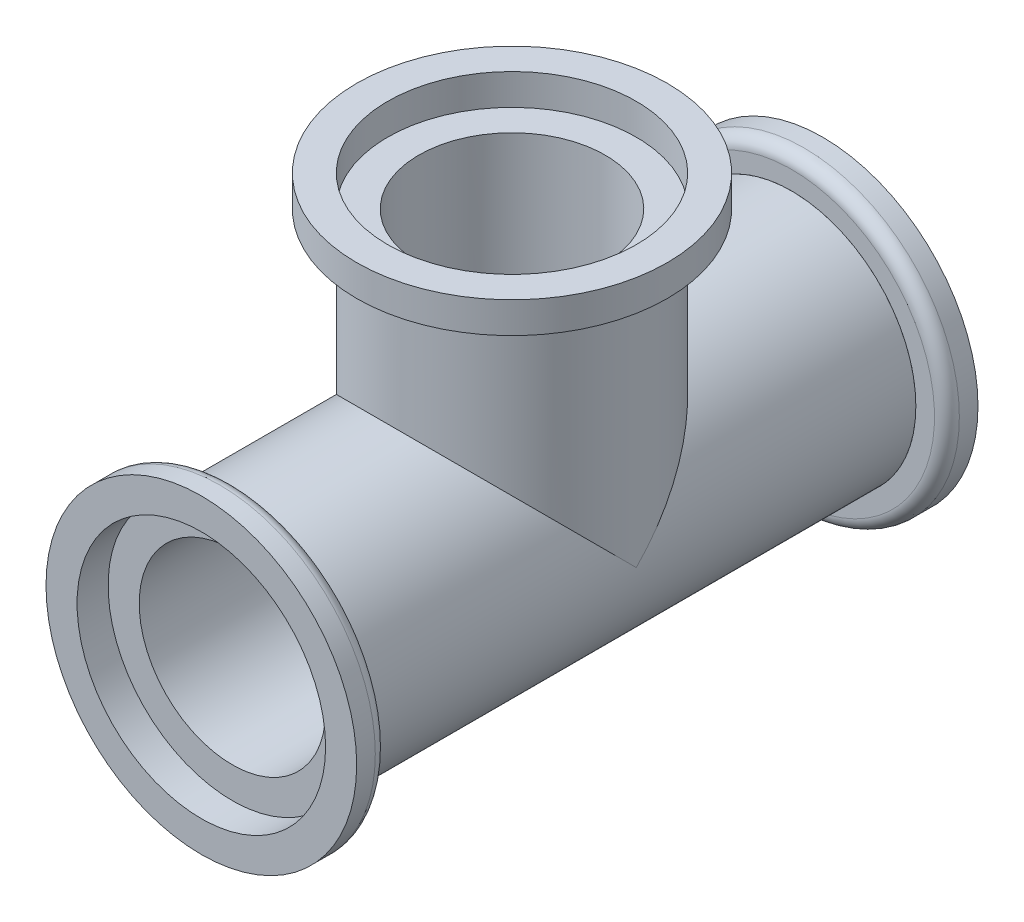
from build123d import *

# Parameters (mm, degrees)
SALIENTE_EXTRUIR1_DEPTH      = 22.5
SALIENTE_EXTRUIR1_DEPTH_BACK = 22.5
CROQUIS2_R                   = 10
CROQUIS2_R_2                 = 7.5
CROQUIS3_R                   = 12.5
CROQUIS3_R_2                 = 10
SALIENTE_EXTRUIR2_DEPTH      = 2.5
REDONDEO1_R                  = 1
CROQUIS4_R                   = 12.5
CROQUIS4_R_2                 = 10
SALIENTE_EXTRUIR3_DEPTH      = 2.5
REDONDEO2_R                  = 1
SALIENTE_EXTRUIR4_REACH      = 44.866
CROQUIS5_R                   = 10
CROQUIS5_R_2                 = 7.5
CROQUIS7_R                   = 12.5
CROQUIS7_R_2                 = 10
SALIENTE_EXTRUIR5_DEPTH      = 2.5
CROQUIS8_R                   = 7.5
CORTAR_EXTRUIR4_DEPTH        = 18.5


with BuildPart() as part:
    # Croquis2 → Saliente-Extruir1 (new, two sides: drawn at the far end of the back side and taken through both)
    with BuildSketch(Plane.XY.offset(-SALIENTE_EXTRUIR1_DEPTH_BACK)):
        Circle(CROQUIS2_R)
        Circle(CROQUIS2_R_2, mode=Mode.SUBTRACT)
    extrude(amount=SALIENTE_EXTRUIR1_DEPTH + SALIENTE_EXTRUIR1_DEPTH_BACK)

    # Croquis5 → Saliente-Extruir4 (add, up to next)
    with BuildSketch(Plane(origin=(0, 20, 0), x_dir=(1, 0, 0), z_dir=(0, 1, 0)), mode=Mode.PRIVATE) as saliente_extruir4_sk1:
        Circle(CROQUIS5_R)
        Circle(CROQUIS5_R_2, mode=Mode.SUBTRACT)
    saliente_extruir4_tool1 = extrude(saliente_extruir4_sk1.sketch, amount=-SALIENTE_EXTRUIR4_REACH, mode=Mode.PRIVATE) - part.part
    add(saliente_extruir4_tool1.solids().sort_by_distance((-9.717157, 20, 0))[0])

    # Croquis8 → Cortar-Extruir4 (cut)
    with BuildSketch(Plane(origin=(0, 20, 0), x_dir=(1, 0, 0), z_dir=(0, 1, 0))):
        Circle(CROQUIS8_R)
    extrude(amount=-CORTAR_EXTRUIR4_DEPTH, mode=Mode.SUBTRACT)


with BuildPart() as body_2:
    # Croquis3 → Saliente-Extruir2 (new body)
    with BuildSketch(Plane.XY.offset(22.5)):
        Circle(CROQUIS3_R)
        Circle(CROQUIS3_R_2, mode=Mode.SUBTRACT)
    extrude(amount=SALIENTE_EXTRUIR2_DEPTH)

    # Redondeo1
    redondeo1_edges = [body_2.edges().sort_by_distance(p)[0] for p in [
        (-12.5, 0, 22.5),
    ]]
    fillet(redondeo1_edges, radius=REDONDEO1_R)


with BuildPart() as body_3:
    # Croquis4 → Saliente-Extruir3 (new body)
    with BuildSketch(Plane(origin=(0, 0, -22.5), x_dir=(-1, 0, 0), z_dir=(0, 0, -1))):
        Circle(CROQUIS4_R)
        Circle(CROQUIS4_R_2, mode=Mode.SUBTRACT)
    extrude(amount=SALIENTE_EXTRUIR3_DEPTH)

    # Redondeo2
    redondeo2_edges = [body_3.edges().sort_by_distance(p)[0] for p in [
        (12.5, 0, -22.5),
    ]]
    fillet(redondeo2_edges, radius=REDONDEO2_R)


with BuildPart() as body_4:
    # Croquis7 → Saliente-Extruir5 (new body)
    with BuildSketch(Plane(origin=(0, 20, 0), x_dir=(1, 0, 0), z_dir=(0, 1, 0))):
        Circle(CROQUIS7_R)
        Circle(CROQUIS7_R_2, mode=Mode.SUBTRACT)
    extrude(amount=SALIENTE_EXTRUIR5_DEPTH)


solid = Compound([part.part, body_2.part, body_3.part, body_4.part])
